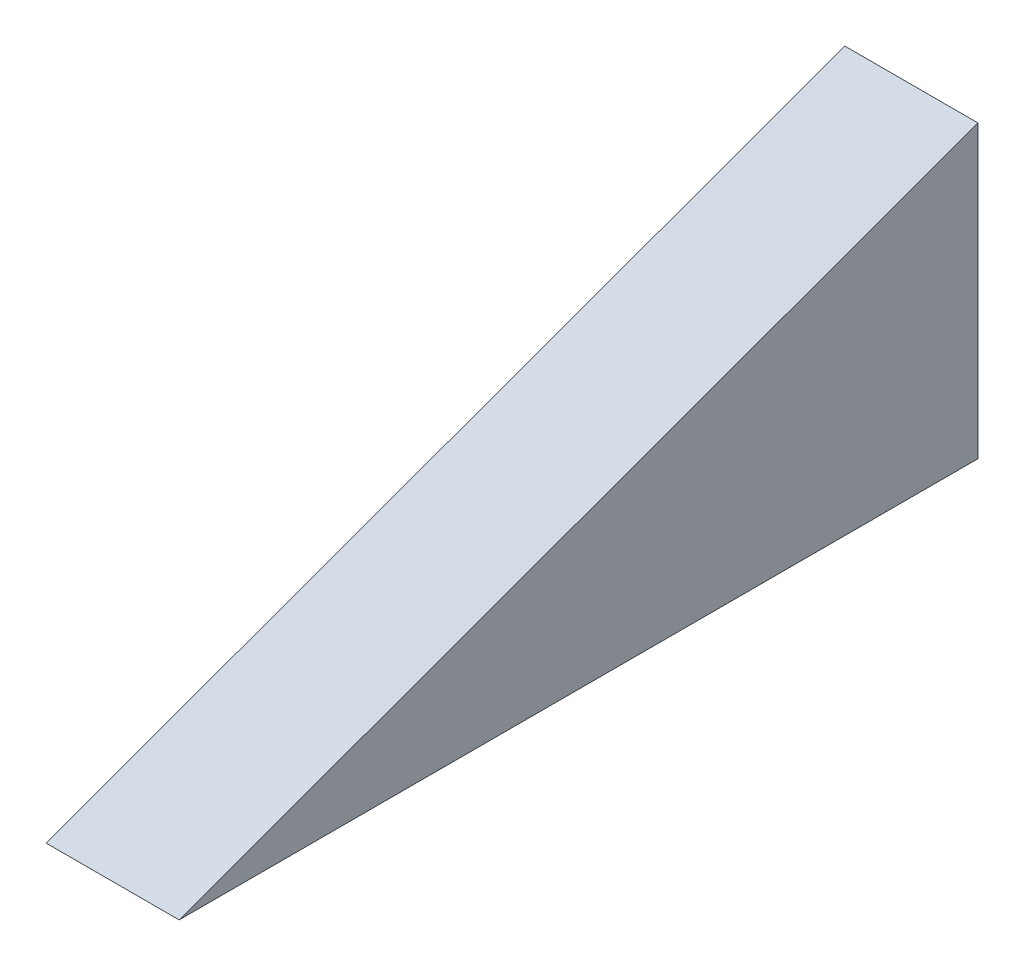
from build123d import *

# Parameters (mm, degrees)
BOSS_EXTRUDE1_DEPTH = 25.4


with BuildPart() as part:
    # Sketch1 → Boss-Extrude1 (new body)
    with BuildSketch(Plane(origin=(0, 0, 0), x_dir=(0, 0, -1), z_dir=(1, 0, 0))):
        Polygon((0, 0), (152.4, 0), (152.4, 55.469063702), align=None)
    extrude(amount=BOSS_EXTRUDE1_DEPTH)


solid = part.part
